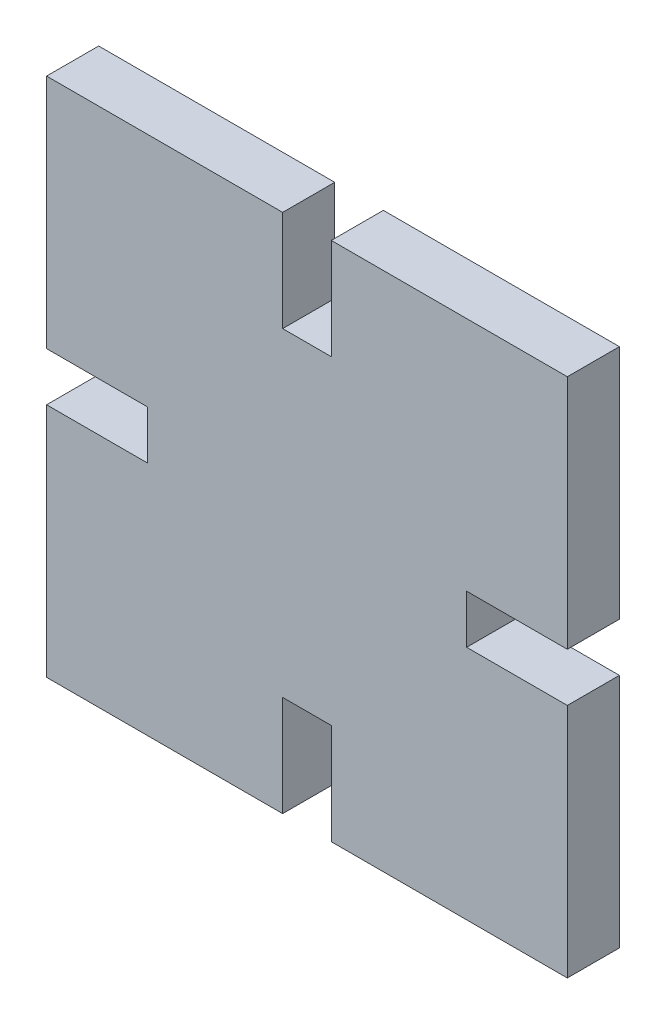
from build123d import *

# Parameters (mm, degrees)
SKETCH1_W               = 30
SKETCH1_H               = 30
BOSS_EXTRUDE1_DEPTH     = 3
SKETCH2_W               = 2.8
SKETCH2_H               = 5.8
SKETCH2_W_2             = 5.8
SKETCH2_H_2             = 2.8
CUT_EXTRUDE1_DEPTH      = 1
CUT_EXTRUDE1_DEPTH_BACK = 4


with BuildPart() as part:
    # Sketch1 → Boss-Extrude1 (new body)
    with BuildSketch(Plane.XY):
        Rectangle(SKETCH1_W, SKETCH1_H)
    extrude(amount=BOSS_EXTRUDE1_DEPTH)

    # Sketch2 → Cut-Extrude1 (cut, two sides)
    with BuildSketch(Plane.XY.offset(3)) as cut_extrude1_sk:
        with Locations((0, 12.1)):
            Rectangle(SKETCH2_W, SKETCH2_H)
        with Locations((0, -12.1)):
            Rectangle(SKETCH2_W, SKETCH2_H)
        with Locations((-12.1, 0)):
            Rectangle(SKETCH2_W_2, SKETCH2_H_2)
        with Locations((12.1, 0)):
            Rectangle(SKETCH2_W_2, SKETCH2_H_2)
    extrude(amount=CUT_EXTRUDE1_DEPTH, mode=Mode.SUBTRACT)
    extrude(cut_extrude1_sk.sketch, amount=-CUT_EXTRUDE1_DEPTH_BACK, mode=Mode.SUBTRACT)


solid = part.part
